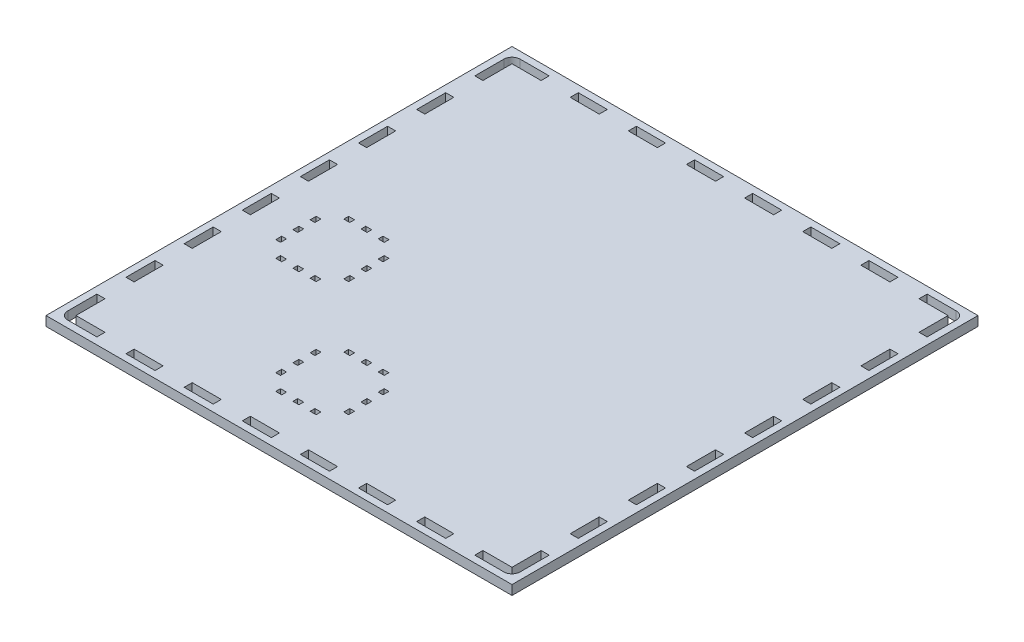
from build123d import *

# Parameters (mm, degrees)
SKETCH1_W           = 311.4
SKETCH1_H           = 311.4
SKETCH1_W_2         = 5.4
SKETCH1_H_2         = 19.425
SKETCH1_W_3         = 19.425
SKETCH1_H_3         = 5.4
SKETCH1_W_4         = 4.000000243
SKETCH1_H_4         = 3.174999693
SKETCH1_W_5         = 3.175000307
SKETCH1_H_5         = 3.999999757
SKETCH1_H_6         = 3.999999756
SKETCH1_W_6         = 4
SKETCH1_H_7         = 3.175
SKETCH1_W_7         = 3.175
SKETCH1_H_8         = 4
SKETCH1_W_8         = 3.174999693
SKETCH1_H_9         = 4.000000243
SKETCH1_H_10        = 4.000000244
BOSS_EXTRUDE4_DEPTH = 6.35
SKETCH4_W           = 19.425
SKETCH4_H           = 5.4
SKETCH4_W_2         = 5.4
SKETCH4_H_2         = 19.425
CUT_EXTRUDE3_DEPTH  = 6.35


with BuildPart() as part:
    # Sketch1 → Boss-Extrude4 (new body)
    with BuildSketch(Plane(origin=(0, 0, 0), x_dir=(1, 0, 0), z_dir=(0, 1, 0))):
        with Locations((148.1875, 148.2125)):
            Rectangle(SKETCH1_W, SKETCH1_H)
        with Locations((-0.2125, 51.075)):
            Rectangle(SKETCH1_W_2, SKETCH1_H_2, mode=Mode.SUBTRACT)
        with Locations((-0.2125, 89.925)):
            Rectangle(SKETCH1_W_2, SKETCH1_H_2, mode=Mode.SUBTRACT)
        with Locations((-0.2125, 128.775)):
            Rectangle(SKETCH1_W_2, SKETCH1_H_2, mode=Mode.SUBTRACT)
        with Locations((-0.2125, 167.625)):
            Rectangle(SKETCH1_W_2, SKETCH1_H_2, mode=Mode.SUBTRACT)
        with Locations((-0.2125, 206.475)):
            Rectangle(SKETCH1_W_2, SKETCH1_H_2, mode=Mode.SUBTRACT)
        with Locations((-0.2125, 245.325)):
            Rectangle(SKETCH1_W_2, SKETCH1_H_2, mode=Mode.SUBTRACT)
        with Locations((51.075, 296.6125)):
            Rectangle(SKETCH1_W_3, SKETCH1_H_3, mode=Mode.SUBTRACT)
        with Locations((89.925, 296.6125)):
            Rectangle(SKETCH1_W_3, SKETCH1_H_3, mode=Mode.SUBTRACT)
        with Locations((128.775, 296.6125)):
            Rectangle(SKETCH1_W_3, SKETCH1_H_3, mode=Mode.SUBTRACT)
        with Locations((167.625, 296.6125)):
            Rectangle(SKETCH1_W_3, SKETCH1_H_3, mode=Mode.SUBTRACT)
        with Locations((206.475, 296.6125)):
            Rectangle(SKETCH1_W_3, SKETCH1_H_3, mode=Mode.SUBTRACT)
        with Locations((245.325, 296.6125)):
            Rectangle(SKETCH1_W_3, SKETCH1_H_3, mode=Mode.SUBTRACT)
        with Locations((296.5875, 245.35)):
            Rectangle(SKETCH1_W_2, SKETCH1_H_2, mode=Mode.SUBTRACT)
        with Locations((296.5875, 206.5)):
            Rectangle(SKETCH1_W_2, SKETCH1_H_2, mode=Mode.SUBTRACT)
        with Locations((296.5875, 167.65)):
            Rectangle(SKETCH1_W_2, SKETCH1_H_2, mode=Mode.SUBTRACT)
        with Locations((296.5875, 128.8)):
            Rectangle(SKETCH1_W_2, SKETCH1_H_2, mode=Mode.SUBTRACT)
        with Locations((296.5875, 89.95)):
            Rectangle(SKETCH1_W_2, SKETCH1_H_2, mode=Mode.SUBTRACT)
        with Locations((296.5875, 51.1)):
            Rectangle(SKETCH1_W_2, SKETCH1_H_2, mode=Mode.SUBTRACT)
        with Locations((245.3, -0.1875)):
            Rectangle(SKETCH1_W_3, SKETCH1_H_3, mode=Mode.SUBTRACT)
        with Locations((206.45, -0.1875)):
            Rectangle(SKETCH1_W_3, SKETCH1_H_3, mode=Mode.SUBTRACT)
        with Locations((167.6, -0.1875)):
            Rectangle(SKETCH1_W_3, SKETCH1_H_3, mode=Mode.SUBTRACT)
        with Locations((128.75, -0.1875)):
            Rectangle(SKETCH1_W_3, SKETCH1_H_3, mode=Mode.SUBTRACT)
        with Locations((89.9, -0.1875)):
            Rectangle(SKETCH1_W_3, SKETCH1_H_3, mode=Mode.SUBTRACT)
        with Locations((51.05, -0.1875)):
            Rectangle(SKETCH1_W_3, SKETCH1_H_3, mode=Mode.SUBTRACT)
        with Locations((38.162499879, 149.42500074)):
            Rectangle(SKETCH1_W_4, SKETCH1_H_4, mode=Mode.SUBTRACT)
        with Locations((49.662499879, 149.42500074)):
            Rectangle(SKETCH1_W_4, SKETCH1_H_4, mode=Mode.SUBTRACT)
        with Locations((61.162499879, 149.42500074)):
            Rectangle(SKETCH1_W_4, SKETCH1_H_4, mode=Mode.SUBTRACT)
        with Locations((72.40000236, 138.187501742)):
            Rectangle(SKETCH1_W_5, SKETCH1_H_5, mode=Mode.SUBTRACT)
        with Locations((72.40000236, 126.68750181)):
            Rectangle(SKETCH1_W_5, SKETCH1_H_5, mode=Mode.SUBTRACT)
        with Locations((72.40000236, 115.187501877)):
            Rectangle(SKETCH1_W_5, SKETCH1_H_6, mode=Mode.SUBTRACT)
        with Locations((61.162501621, 103.95)):
            Rectangle(SKETCH1_W_6, SKETCH1_H_7, mode=Mode.SUBTRACT)
        with Locations((49.662501621, 103.95)):
            Rectangle(SKETCH1_W_6, SKETCH1_H_7, mode=Mode.SUBTRACT)
        with Locations((38.162501621, 103.95)):
            Rectangle(SKETCH1_W_6, SKETCH1_H_7, mode=Mode.SUBTRACT)
        with Locations((26.925001621, 115.1875)):
            Rectangle(SKETCH1_W_7, SKETCH1_H_8, mode=Mode.SUBTRACT)
        with Locations((26.925001621, 126.6875)):
            Rectangle(SKETCH1_W_7, SKETCH1_H_8, mode=Mode.SUBTRACT)
        with Locations((26.925001621, 138.1875)):
            Rectangle(SKETCH1_W_7, SKETCH1_H_8, mode=Mode.SUBTRACT)
        with Locations((115.162499879, 72.42500074)):
            Rectangle(SKETCH1_W_4, SKETCH1_H_4, mode=Mode.SUBTRACT)
        with Locations((126.662499879, 72.42500074)):
            Rectangle(SKETCH1_W_4, SKETCH1_H_4, mode=Mode.SUBTRACT)
        with Locations((138.162499879, 72.42500074)):
            Rectangle(SKETCH1_W_4, SKETCH1_H_4, mode=Mode.SUBTRACT)
        with Locations((149.400002361, 61.187501743)):
            Rectangle(SKETCH1_W_8, SKETCH1_H_9, mode=Mode.SUBTRACT)
        with Locations((149.400002361, 49.68750181)):
            Rectangle(SKETCH1_W_8, SKETCH1_H_9, mode=Mode.SUBTRACT)
        with Locations((149.400002361, 38.187501877)):
            Rectangle(SKETCH1_W_8, SKETCH1_H_10, mode=Mode.SUBTRACT)
        with Locations((138.162501621, 26.95)):
            Rectangle(SKETCH1_W_6, SKETCH1_H_7, mode=Mode.SUBTRACT)
        with Locations((126.662501621, 26.95)):
            Rectangle(SKETCH1_W_6, SKETCH1_H_7, mode=Mode.SUBTRACT)
        with Locations((115.162501621, 26.95)):
            Rectangle(SKETCH1_W_6, SKETCH1_H_7, mode=Mode.SUBTRACT)
        with Locations((103.925001621, 38.1875)):
            Rectangle(SKETCH1_W_7, SKETCH1_H_8, mode=Mode.SUBTRACT)
        with Locations((103.925001621, 49.6875)):
            Rectangle(SKETCH1_W_7, SKETCH1_H_8, mode=Mode.SUBTRACT)
        with Locations((103.925001621, 61.1875)):
            Rectangle(SKETCH1_W_7, SKETCH1_H_8, mode=Mode.SUBTRACT)
    extrude(amount=BOSS_EXTRUDE4_DEPTH)

    # Sketch4 → Cut-Extrude3 (cut)
    with BuildSketch(Plane(origin=(0, 6.35, 0), x_dir=(1, 0, 0), z_dir=(0, 1, 0))):
        with Locations((12.225, 296.6125)):
            Rectangle(SKETCH4_W, SKETCH4_H)
        with Locations((-0.2125, 284.175)):
            Rectangle(SKETCH4_W_2, SKETCH4_H_2)
        with BuildLine():
            ThreePointArc((2.512500017, 299.287442129), (-1.322027524, 297.714705253), (-2.9125, 293.8875))
            Line((-2.9125, 293.8875), (2.4875, 293.8875))
            Line((2.4875, 293.8875), (2.5125, 293.9125))
            Line((2.5125, 293.9125), (2.5125, 299.287442129))
        make_face()
        with BuildLine():
            Line((293.8875, 293.9125), (299.2875, 293.9125))
            ThreePointArc((299.2875, 293.9125), (297.705876618, 297.730876618), (293.8875, 299.3125))
            Line((293.8875, 299.3125), (293.8875, 293.9125))
        make_face()
        with Locations((284.175, 296.6125)):
            Rectangle(SKETCH4_W, SKETCH4_H)
        with Locations((296.5875, 284.2)):
            Rectangle(SKETCH4_W_2, SKETCH4_H_2)
        with Locations((-0.2125, 12.225)):
            Rectangle(SKETCH4_W_2, SKETCH4_H_2)
        with Locations((12.2, -0.1875)):
            Rectangle(SKETCH4_W, SKETCH4_H)
        with BuildLine():
            ThreePointArc((2.4875, -2.8875), (-1.330876618, -1.305876618), (-2.9125, 2.5125))
            Line((-2.9125, 2.5125), (2.4875, 2.5125))
            Line((2.4875, 2.5125), (2.4875, -2.8875))
        make_face()
        with BuildLine():
            Line((293.8875, 2.5375), (293.8625, 2.5125))
            Line((293.8625, 2.5125), (293.8625, -2.8875))
            ThreePointArc((293.8625, -2.8875), (297.689705247, -1.29702753), (299.262442129, 2.5375))
            Line((299.262442129, 2.5375), (293.8875, 2.5375))
        make_face()
        with Locations((284.15, -0.1875)):
            Rectangle(SKETCH4_W, SKETCH4_H)
        with Locations((296.5875, 12.25)):
            Rectangle(SKETCH4_W_2, SKETCH4_H_2)
    extrude(amount=-CUT_EXTRUDE3_DEPTH, mode=Mode.SUBTRACT)


solid = part.part
